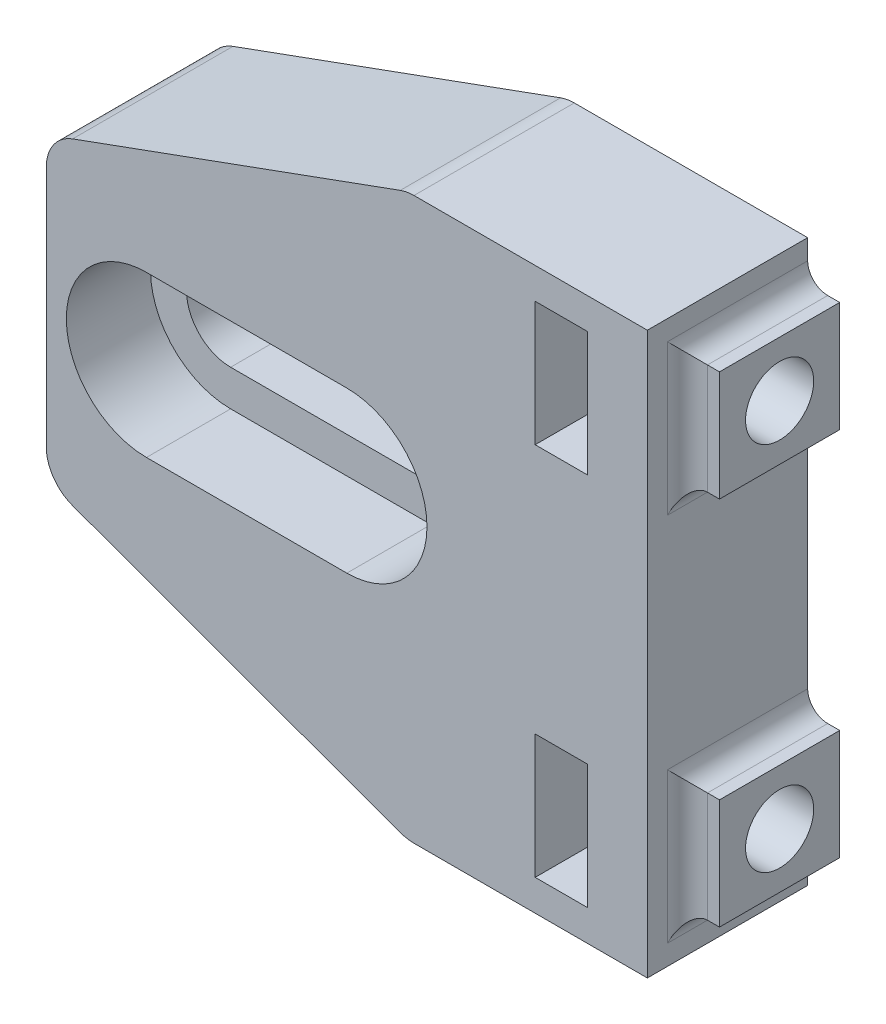
from build123d import *

# Parameters (mm, degrees)
ESQUISSE1_W             = 30
ESQUISSE1_H             = 28
BOSS_EXTRU_1_DEPTH      = 8
ENL_V_MAT_EXTRU_1_DEPTH = 9
ENL_V_MAT_EXTRU_2_DEPTH = 4.2
CHANFREIN1_SIZE         = 18
CHANFREIN1_SIZE2        = 6.551464217
CHANFREIN1_PART_2_SIZE  = 18
CHANFREIN1_PART_2_SIZE2 = 6.551464217
CONG_1_R                = 2
ESQUISSE4_W             = 2.6
ESQUISSE4_H             = 6.2
ENL_V_MAT_EXTRU_3_DEPTH = 9
ESQUISSE5_R             = 1.7
ENL_V_MAT_EXTRU_4_DEPTH = 16
ESQUISSE6_W             = 6
ESQUISSE6_H             = 5.5
ESQUISSE6_R             = 1.7
BOSS_EXTRU_2_DEPTH      = 1.6
CONG_2_R                = 1


with BuildPart() as part:
    # Esquisse1 → Boss.-Extru.1 (new body)
    with BuildSketch(Plane.XY):
        with Locations((7, 0)):
            Rectangle(ESQUISSE1_W, ESQUISSE1_H)
    extrude(amount=BOSS_EXTRU_1_DEPTH)

    # Esquisse2 → Enlèv. mat.-Extru.1 (cut, through all)
    with BuildSketch(Plane.XY.offset(8)):
        with BuildLine():
            Line((-3, 2.2), (7, 2.2))
            ThreePointArc((7, 2.2), (9.2, 0), (7, -2.2))
            Line((7, -2.2), (-3, -2.2))
            ThreePointArc((-3, -2.2), (-5.2, 0), (-3, 2.2))
        make_face()
    extrude(amount=-ENL_V_MAT_EXTRU_1_DEPTH, mode=Mode.SUBTRACT)

    # Esquisse3 → Enlèv. mat.-Extru.2 (cut)
    with BuildSketch(Plane.XY.offset(8)):
        with BuildLine():
            Line((-3, 4), (7, 4))
            ThreePointArc((7, 4), (11, 0), (7, -4))
            Line((7, -4), (-3, -4))
            ThreePointArc((-3, -4), (-7, 0), (-3, 4))
        make_face()
    extrude(amount=-ENL_V_MAT_EXTRU_2_DEPTH, mode=Mode.SUBTRACT)

    # Chanfrein1
    chanfrein1_edges = [part.edges().sort_by_distance(p)[0] for p in [
        (-8, 14, 4),
    ]]
    chanfrein1_side = [part.faces().sort_by_distance(p)[0] for p in [
        (7, 14, 4),
    ]]
    chamfer(chanfrein1_edges, length=CHANFREIN1_SIZE, length2=CHANFREIN1_SIZE2, reference=chanfrein1_side[0])

    # Chanfrein1 part 2
    chanfrein1_part_2_edges = [part.edges().sort_by_distance(p)[0] for p in [
        (-8, -14, 4),
    ]]
    chanfrein1_part_2_side = [part.faces().sort_by_distance(p)[0] for p in [
        (7, -14, 4),
    ]]
    chamfer(chanfrein1_part_2_edges, length=CHANFREIN1_PART_2_SIZE, length2=CHANFREIN1_PART_2_SIZE2, reference=chanfrein1_part_2_side[0])

    # Congé1
    cong_1_edges = [part.edges().sort_by_distance(p)[0] for p in [
        (10, -14, 4),
        (-8, 7.448535783, 4),
        (-8, -7.448535783, 4),
        (10, 14, 4),
    ]]
    fillet(cong_1_edges, radius=CONG_1_R)

    # Esquisse4 → Enlèv. mat.-Extru.3 (cut, through all)
    with BuildSketch(Plane(origin=(0, 0, 0), x_dir=(-1, 0, 0), z_dir=(0, 0, -1))):
        with Locations((-17.7, -9.35)):
            Rectangle(ESQUISSE4_W, ESQUISSE4_H)
        with Locations((-17.7, 9.35)):
            Rectangle(ESQUISSE4_W, ESQUISSE4_H)
    extrude(amount=-ENL_V_MAT_EXTRU_3_DEPTH, mode=Mode.SUBTRACT)

    # Esquisse5 → Enlèv. mat.-Extru.4 (cut)
    with BuildSketch(Plane(origin=(22, 0, 0), x_dir=(0, 0, -1), z_dir=(1, 0, 0))):
        with Locations((-3, 9.25)):
            Circle(ESQUISSE5_R)
        with Locations((-3, -9.25)):
            Circle(ESQUISSE5_R)
    extrude(amount=-ENL_V_MAT_EXTRU_4_DEPTH, mode=Mode.SUBTRACT)

    # Esquisse6 → Boss.-Extru.2 (add)
    with BuildSketch(Plane(origin=(22, 0, 0), x_dir=(0, 0, -1), z_dir=(1, 0, 0))):
        with Locations((-3, -9.25)):
            Rectangle(ESQUISSE6_W, ESQUISSE6_H)
        with Locations((-3, -9.25)):
            Circle(ESQUISSE6_R, mode=Mode.SUBTRACT)
        with Locations((-3, 9.25)):
            Rectangle(ESQUISSE6_W, ESQUISSE6_H)
        with Locations((-3, 9.25)):
            Circle(ESQUISSE6_R, mode=Mode.SUBTRACT)
    extrude(amount=BOSS_EXTRU_2_DEPTH)

    # Congé2
    cong_2_edges = [part.edges().sort_by_distance(p)[0] for p in [
        (22, -12, 3),
        (22, 6.5, 3),
        (22, -9.25, 6),
        (22, -6.5, 3),
        (22, 9.25, 6),
        (22, 12, 3),
    ]]
    fillet(cong_2_edges, radius=CONG_2_R)


solid = part.part
